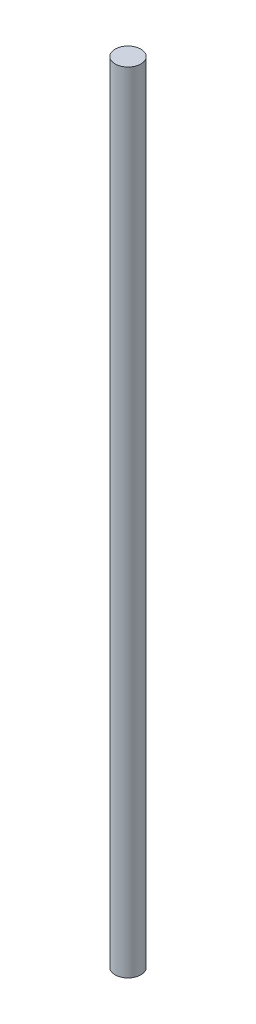
from build123d import *

# Parameters (mm, degrees)
SKETCH_1_W = 4
SKETCH_1_H = 245


with BuildPart() as part:
    # 草图1 → 旋转1 (revolve)
    with BuildSketch(Plane(origin=(0, 0, 0), x_dir=(-1, 0, 0), z_dir=(0, 0, -1))):
        with Locations((-162, -122.5)):
            Rectangle(SKETCH_1_W, SKETCH_1_H)
    revolve(axis=Axis((160, -245, 0), (0, 1, 0)))


solid = part.part
